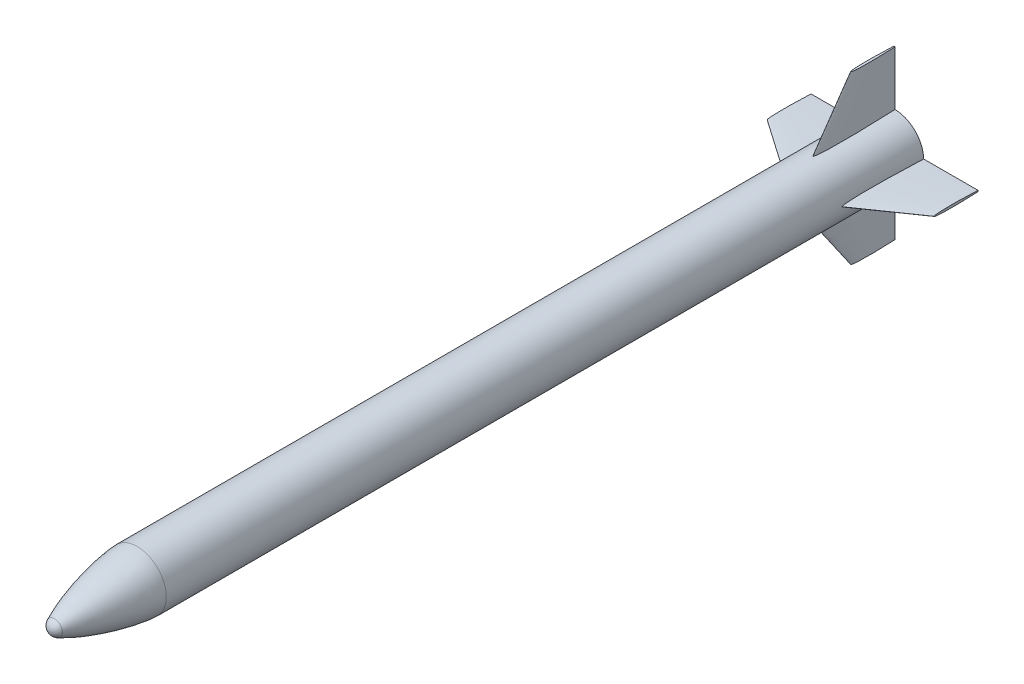
from build123d import *

# Parameters (mm, degrees)
SKETCH3_R           = 43.942
BOSS_EXTRUDE1_DEPTH = 15.24
SKETCH4_W           = 3.175
SKETCH4_H           = 203.2
BOSS_EXTRUDE2_DEPTH = 175.693028
CUT_EXTRUDE1_DEPTH  = 3.175
SKETCH8_W           = 7.50506191
SKETCH8_H           = 49.986746891
CUT_EXTRUDE3_DEPTH  = 147.251971663
CIRPATTERN1_COUNT   = 4


with BuildPart() as part:
    # Sketch2 → Revolve1 (revolve)
    with BuildSketch(Plane(origin=(0, 0, 0), x_dir=(0, 0, -1), z_dir=(1, 0, 0))):
        with BuildLine():
            Line((253.999717939, 78.323061455), (2289.492217939, 78.323061455))
            Line((2289.492217939, 78.323061455), (2289.492217939, 0.000129455))
            Line((2289.492217939, 0.000129455), (18.722754206, 0.000129455))
            ThreePointArc((18.722754206, 0.000129455), (22.321044278, 12.496108239), (32.013836971, 21.164842114))
            add(Edge.make_bspline(
                [(32.013836971, 21.164842114), (32.371281307, 21.337204684), (33.092031762, 21.682884594), (34.459942664, 22.334207306), (35.920170868, 23.016773974), (37.960823583, 23.961231762), (40.309597456, 25.026973682), (43.198275007, 26.312421522), (46.53765354, 27.760550401), (49.911628086, 29.189780931), (53.284145411, 30.584903326), (57.408249136, 32.255071948), (62.279598162, 34.174743769), (67.990284004, 36.353888296), (73.724859576, 38.462747782), (78.658111989, 40.224362249), (83.603322825, 41.949913738), (88.560938842, 43.640745085), (94.361157192, 45.564114848), (101.011274997, 47.697466488), (107.681125646, 49.767972951), (114.369702519, 51.777325291), (121.075960211, 53.726734924), (129.479888269, 56.089741087), (139.59689085, 58.808506128), (151.444455774, 61.811360433), (165.0417333, 65.009092759), (178.693560428, 67.965580707), (192.398133151, 70.667498406), (206.154420099, 73.093520705), (218.306348782, 74.955460643), (228.765275439, 76.320134365), (237.400698068, 77.255084307), (243.106821619, 77.760556072), (247.542083442, 78.068682527), (250.507953566, 78.221012738), (252.115741265, 78.284137305), (253.189863339, 78.313468048), (253.729746804, 78.321171152), (253.999717939, 78.323061455)],
                knots=[0.090849304, 0.090849304, 0.090849304, 0.090849304, 0.090849304, 0.097738989, 0.104628673, 0.111518358, 0.118408042, 0.132187372, 0.145966701, 0.161033393, 0.176100084, 0.189879424, 0.203658764, 0.231217444, 0.258776134, 0.286334823, 0.30011417, 0.313893518, 0.341452213, 0.3690109, 0.396569587, 0.424128278, 0.451686968, 0.479245657, 0.506804345, 0.561921727, 0.617039106, 0.672156482, 0.727273864, 0.782391239, 0.837508619, 0.892626001, 0.921305162, 0.948863847, 0.974602784, 0.98304005, 0.991477316, 0.995738658, 1, 1, 1, 1, 1], degree=4))
        make_face()
    revolve(axis=Axis((0, 0.000129455, -2289.492217939), (0, 0, 1)))

    # Sketch3 → Boss-Extrude1 (add)
    with BuildSketch(Plane(origin=(0, 0, -2289.492217939), x_dir=(-1, 0, 0), z_dir=(0, 0, -1))):
        Circle(SKETCH3_R)
    extrude(amount=BOSS_EXTRUDE1_DEPTH)

    # Sketch4 → Boss-Extrude2 (add)
    with BuildSketch(Plane(origin=(0, 254, 0), x_dir=(1, 0, 0), z_dir=(0, 1, 0))):
        with Locations((0, 2184.717217939)):
            Rectangle(SKETCH4_W, SKETCH4_H)
    boss_extrude2 = extrude(amount=-BOSS_EXTRUDE2_DEPTH)

    # Sketch5 → Cut-Extrude1 (cut)
    with BuildSketch(Plane.ZY.offset(1.5875)):
        Polygon((-2286.317217939, 224.356971563), (-2184.717217939, 224.356971563), (-2083.117217939, 78.306971563), (-2083.117217939, 254), (-2286.317217939, 254), align=None)
    cut_extrude1 = extrude(amount=-CUT_EXTRUDE1_DEPTH, mode=Mode.SUBTRACT)

    # Sketch6 → Loft12 section 0
    with BuildSketch(Plane(origin=(0, 224.356971563, 0), x_dir=(1, 0, 0), z_dir=(0, 1, 0))):
        with BuildLine():
            add(Edge.make_bspline(
                [(0, 2171.7), (0.051023025, 2171.700648282), (0.123073762, 2171.713903143), (0.20868098, 2171.754165542), (0.306157837, 2171.828428146), (0.38077584, 2171.901401687), (0.459239223, 2171.995621491), (0.552747398, 2172.131901904), (0.67112201, 2172.341534489), (0.836676052, 2172.705674314), (1.091383201, 2173.433960229), (1.386540708, 2174.608089462), (1.683612322, 2176.186719151), (2.047714994, 2178.689894638), (2.395674972, 2181.901770917), (2.843561273, 2187.452013643), (3.233815395, 2195.347274659), (3.484465724, 2204.973743405), (3.565733066, 2216.324694259), (3.497304061, 2227.678560982), (3.316930215, 2239.026317509), (3.050599853, 2250.380330588), (2.758835231, 2260.300803769), (2.473165566, 2268.822634779), (2.164545402, 2277.309451419), (1.884603368, 2284.442277183), (1.592982913, 2291.455089252), (1.272905783, 2298.655354604), (1.021298601, 2304.13369712), (0.728615668, 2310.150742323), (0.476201594, 2315.218638113), (0.210201711, 2320.238969009), (0.070930363, 2322.811698128), (0, 2324.100018295)],
                knots=[0, 0, 0, 0, 0, 0.001188773, 0.001744604, 0.002211261, 0.002902454, 0.003665217, 0.004655039, 0.006134761, 0.008618592, 0.013161868, 0.022971681, 0.034880856, 0.046790031, 0.073273565, 0.0997571, 0.167217454, 0.23467781, 0.302138166, 0.369598523, 0.437058879, 0.504519235, 0.571979591, 0.60570977, 0.639439948, 0.706900304, 0.740630482, 0.77436066, 0.808090839, 0.841821017, 0.875551195, 0.909281373, 0.909281373, 0.909281373, 0.909281373, 0.909281373], degree=4))
            add(Edge.make_bspline(
                [(0, 2171.7), (-0.051023025, 2171.700648282), (-0.123073762, 2171.713903143), (-0.20868098, 2171.754165542), (-0.306157837, 2171.828428146), (-0.38077584, 2171.901401687), (-0.459239223, 2171.995621491), (-0.552747398, 2172.131901904), (-0.67112201, 2172.341534489), (-0.836676052, 2172.705674314), (-1.091383201, 2173.433960229), (-1.386540708, 2174.608089462), (-1.683612322, 2176.186719151), (-2.047714994, 2178.689894638), (-2.395674972, 2181.901770917), (-2.843561273, 2187.452013643), (-3.233815395, 2195.347274659), (-3.484465724, 2204.973743405), (-3.565733066, 2216.324694259), (-3.497304061, 2227.678560982), (-3.316930215, 2239.026317509), (-3.050599853, 2250.380330588), (-2.758835231, 2260.300803769), (-2.473165566, 2268.822634779), (-2.164545402, 2277.309451419), (-1.884603368, 2284.442277183), (-1.592982913, 2291.455089252), (-1.272905783, 2298.655354604), (-1.021298601, 2304.13369712), (-0.728615668, 2310.150742323), (-0.476201594, 2315.218638113), (-0.210201711, 2320.238969009), (-0.070930363, 2322.811698128), (0, 2324.100018295)],
                knots=[0, 0, 0, 0, 0, 0.001188773, 0.001744604, 0.002211261, 0.002902454, 0.003665217, 0.004655039, 0.006134761, 0.008618592, 0.013161868, 0.022971681, 0.034880856, 0.046790031, 0.073273565, 0.0997571, 0.167217454, 0.23467781, 0.302138166, 0.369598523, 0.437058879, 0.504519235, 0.571979591, 0.60570977, 0.639439948, 0.706900304, 0.740630482, 0.77436066, 0.808090839, 0.841821017, 0.875551195, 0.909281373, 0.909281373, 0.909281373, 0.909281373, 0.909281373], degree=4))
        make_face()
    # Sketch7 → Loft12 section 1
    with BuildSketch(Plane(origin=(0, 78.105, 0), x_dir=(1, 0, 0), z_dir=(0, 1, 0))):
        with BuildLine():
            add(Edge.make_bspline(
                [(0, 2070.1), (0.034219924, 2070.100165249), (0.101433103, 2070.107349373), (0.231578713, 2070.150196993), (0.360328489, 2070.246951985), (0.462507028, 2070.353564142), (0.561959786, 2070.481012431), (0.644614931, 2070.603175552), (0.750526321, 2070.78519167), (0.892167773, 2071.074452021), (1.083903907, 2071.549787837), (1.369429879, 2072.438060657), (1.816145557, 2074.293717739), (2.298808701, 2077.180168637), (2.769987399, 2080.990528328), (3.296814895, 2086.604968322), (3.769686564, 2093.440016864), (4.283475655, 2103.673053012), (4.695953859, 2117.307852477), (4.924993808, 2133.219867535), (4.949672088, 2151.407398455), (4.801833129, 2169.593016337), (4.556982302, 2185.505734367), (4.283038202, 2199.141404202), (3.964939404, 2212.780562475), (3.667273138, 2224.137774842), (3.340204516, 2235.509585415), (2.988306879, 2246.856607416), (2.690431026, 2255.967845223), (2.303497954, 2267.285895323), (1.805042261, 2280.999071732), (1.282003917, 2294.482999268), (0.752405736, 2307.183955871), (0.368402997, 2315.97815155), (0.142501679, 2320.98629114), (0.04750229, 2323.067612156), (0, 2324.100021297)],
                knots=[0, 0, 0, 0, 0, 0.000482574, 0.000965149, 0.001930298, 0.002260301, 0.002590304, 0.003269978, 0.004035031, 0.005264177, 0.007184719, 0.010581715, 0.017344383, 0.032491444, 0.048939298, 0.065387151, 0.097842867, 0.130298584, 0.19521002, 0.260121457, 0.325032894, 0.389944331, 0.454855768, 0.487311487, 0.519767205, 0.584678642, 0.617134361, 0.649590079, 0.682045798, 0.714501516, 0.779412953, 0.84432439, 0.876780109, 0.893007968, 0.909235827, 0.909235827, 0.909235827, 0.909235827, 0.909235827], degree=4))
            add(Edge.make_bspline(
                [(0, 2070.1), (-0.034219924, 2070.100165249), (-0.101433103, 2070.107349373), (-0.231578713, 2070.150196993), (-0.360328489, 2070.246951985), (-0.462507028, 2070.353564142), (-0.561959786, 2070.481012431), (-0.644614931, 2070.603175552), (-0.750526321, 2070.78519167), (-0.892167773, 2071.074452021), (-1.083903907, 2071.549787837), (-1.369429879, 2072.438060657), (-1.816145557, 2074.293717739), (-2.298808701, 2077.180168637), (-2.769987399, 2080.990528328), (-3.296814895, 2086.604968322), (-3.769686564, 2093.440016864), (-4.283475655, 2103.673053012), (-4.695953859, 2117.307852477), (-4.924993808, 2133.219867535), (-4.949672088, 2151.407398455), (-4.801833129, 2169.593016337), (-4.556982302, 2185.505734367), (-4.283038202, 2199.141404202), (-3.964939404, 2212.780562475), (-3.667273138, 2224.137774842), (-3.340204516, 2235.509585415), (-2.988306879, 2246.856607416), (-2.690431026, 2255.967845223), (-2.303497954, 2267.285895323), (-1.805042261, 2280.999071732), (-1.282003917, 2294.482999268), (-0.752405736, 2307.183955871), (-0.368402997, 2315.97815155), (-0.142501679, 2320.98629114), (-0.04750229, 2323.067612156), (0, 2324.100021297)],
                knots=[0, 0, 0, 0, 0, 0.000482574, 0.000965149, 0.001930298, 0.002260301, 0.002590304, 0.003269978, 0.004035031, 0.005264177, 0.007184719, 0.010581715, 0.017344383, 0.032491444, 0.048939298, 0.065387151, 0.097842867, 0.130298584, 0.19521002, 0.260121457, 0.325032894, 0.389944331, 0.454855768, 0.487311487, 0.519767205, 0.584678642, 0.617134361, 0.649590079, 0.682045798, 0.714501516, 0.779412953, 0.84432439, 0.876780109, 0.893007968, 0.909235827, 0.909235827, 0.909235827, 0.909235827, 0.909235827], degree=4))
        make_face()
    loft12 = loft()

    # Sketch8 → Cut-Extrude3 (cut, through all)
    with BuildSketch(Plane.XZ.offset(-78.105)):
        with Locations((-1.209951309, -2314.485591385)):
            Rectangle(SKETCH8_W, SKETCH8_H)
    cut_extrude3 = extrude(amount=-CUT_EXTRUDE3_DEPTH, mode=Mode.SUBTRACT)

    # CirPattern1: Boss-Extrude2, Cut-Extrude1, Loft12, Cut-Extrude3 ×4 about axis
    cirpattern1_axis = Axis((0, 0.000129455, -2289.492217939), (0, 0, -1))
    for i in range(1, CIRPATTERN1_COUNT):
        add(boss_extrude2.rotate(cirpattern1_axis, i * 360 / CIRPATTERN1_COUNT))
        add(cut_extrude1.rotate(cirpattern1_axis, i * 360 / CIRPATTERN1_COUNT), mode=Mode.SUBTRACT)
        add(loft12.rotate(cirpattern1_axis, i * 360 / CIRPATTERN1_COUNT))
        add(cut_extrude3.rotate(cirpattern1_axis, i * 360 / CIRPATTERN1_COUNT), mode=Mode.SUBTRACT)


solid = part.part
